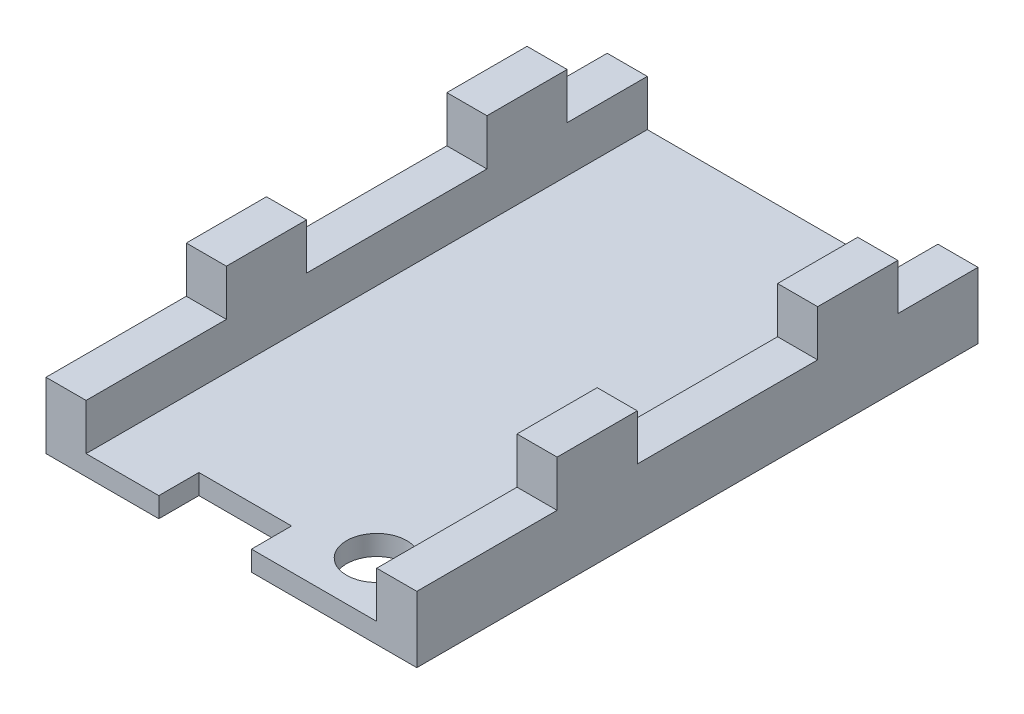
from build123d import *

# Parameters (mm, degrees)
MAIN_BOARD_OUTLINE_W = 18.5
MAIN_BOARD_OUTLINE_H = 28
SIDE1_DEPTH          = 1
SKETCH2_W            = 2
SKETCH2_H            = 28
WALLS_DEPTH          = 2.3
SKETCH3_R            = 1.5
SCREW_HOLE_DEPTH     = 2.3
SKETCH4_W            = 4.6228
SKETCH4_H            = 2
CUT_EXTRUDE2_DEPTH   = 2.3
SKETCH5_W            = 2
SKETCH5_H            = 4
BOSS_EXTRUDE3_DEPTH  = 2.3


with BuildPart() as part:
    # main board outline → side1 (new body)
    with BuildSketch(Plane(origin=(0, 0, 0), x_dir=(1, 0, 0), z_dir=(0, 1, 0))):
        with Locations((-19.997374583, 0.651042113)):
            Rectangle(MAIN_BOARD_OUTLINE_W, MAIN_BOARD_OUTLINE_H)
    extrude(amount=SIDE1_DEPTH)

    # Sketch2 → walls (add)
    with BuildSketch(Plane(origin=(0, 1, 0), x_dir=(1, 0, 0), z_dir=(0, 1, 0))):
        with Locations((-28.247374583, 0.651042113)):
            Rectangle(SKETCH2_W, SKETCH2_H)
        with Locations((-11.747374583, 0.651042113)):
            Rectangle(SKETCH2_W, SKETCH2_H)
    extrude(amount=WALLS_DEPTH)

    # Sketch3 → screw hole (cut)
    with BuildSketch(Plane(origin=(0, 0, 0), x_dir=(-1, 0, 0), z_dir=(0, -1, 0))):
        with Locations((15.490574583, -10.605757887)):
            Circle(SKETCH3_R)
    extrude(amount=-SCREW_HOLE_DEPTH, mode=Mode.SUBTRACT)

    # Sketch4 → Cut-Extrude2 (cut)
    with BuildSketch(Plane(origin=(0, 0, 0), x_dir=(-1, 0, 0), z_dir=(0, -1, 0))):
        with Locations((21.307174583, -12.348957887)):
            Rectangle(SKETCH4_W, SKETCH4_H)
    extrude(amount=-CUT_EXTRUDE2_DEPTH, mode=Mode.SUBTRACT)

    # Sketch5 → Boss-Extrude3 (add)
    with BuildSketch(Plane(origin=(0, 3.3, 0), x_dir=(1, 0, 0), z_dir=(0, 1, 0))):
        with Locations((-28.247374583, 8.651042113)):
            Rectangle(SKETCH5_W, SKETCH5_H)
        with Locations((-28.247374583, -4.348957887)):
            Rectangle(SKETCH5_W, SKETCH5_H)
        with Locations((-11.747374583, 8.651042113)):
            Rectangle(SKETCH5_W, SKETCH5_H)
        with Locations((-11.747374583, -4.348957887)):
            Rectangle(SKETCH5_W, SKETCH5_H)
    extrude(amount=BOSS_EXTRUDE3_DEPTH)


solid = part.part
